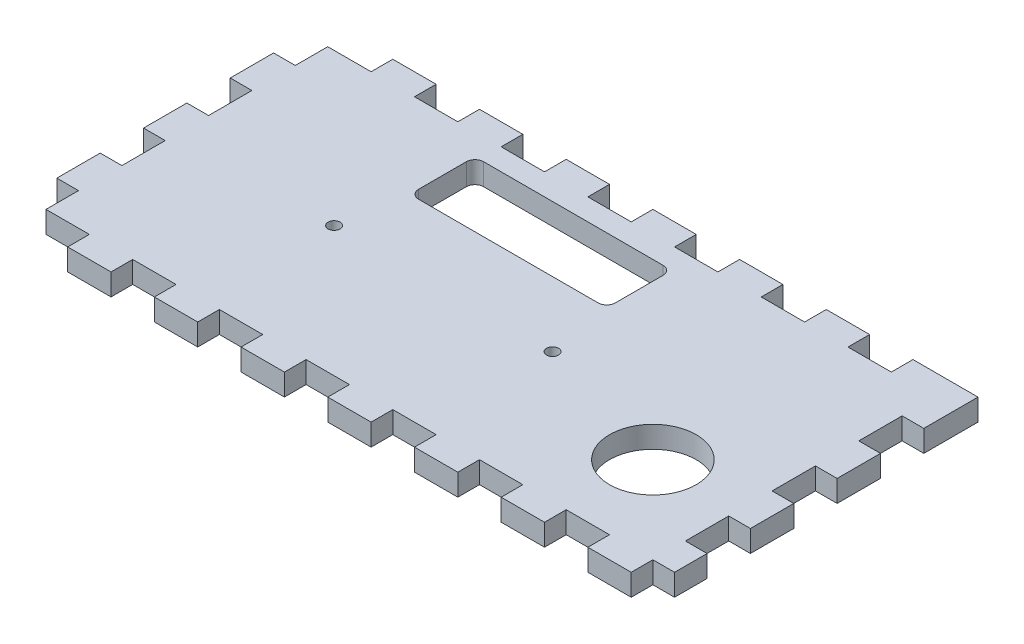
from build123d import *

# Parameters (mm, degrees)
SKETCH1_W           = 431.8
SKETCH1_H           = 95.25
BOSS_EXTRUDE1_DEPTH = 6.35
SKETCH2_W           = 12.7
SKETCH2_H           = 6.35
CUT_EXTRUDE1_DEPTH  = 7.35
LPATTERN1_COUNT     = 17
LPATTERN1_PITCH     = 25.4
SKETCH3_W           = 6.35
SKETCH3_H           = 6.35
CUT_EXTRUDE2_DEPTH  = 7.35
SKETCH5_W           = 6.35
SKETCH5_H           = 12.7
CUT_EXTRUDE4_DEPTH  = 7.35
LPATTERN2_COUNT     = 2
LPATTERN2_PITCH     = 25.4
LPATTERN2_COL_COUNT = 2
LPATTERN2_COL_PITCH = 25.4
SKETCH6_W           = 114.3
SKETCH6_H           = 46.0375
CUT_EXTRUDE5_DEPTH  = 7.35
SKETCH7_R           = 1.75
CUT_EXTRUDE6_DEPTH  = 7.35
SKETCH8_W           = 6.35
SKETCH8_H           = 9.525
SKETCH8_H_2         = 12.7
CUT_EXTRUDE7_DEPTH  = 7.35
LPATTERN3_COUNT     = 2
LPATTERN3_PITCH     = 425.45
SKETCH9_W           = 241.3
SKETCH9_H           = 95.25
CUT_EXTRUDE8_DEPTH  = 7.35
SKETCH11_W          = 6.35
SKETCH11_H          = 6.35
BOSS_EXTRUDE2_DEPTH = 6.35
SKETCH12_W          = 57.65
SKETCH12_H          = 19.05
CUT_EXTRUDE10_DEPTH = 7.35
FILLET1_R           = 2.54
SKETCH13_R          = 12.7
CUT_EXTRUDE11_DEPTH = 7.35


with BuildPart() as part:
    # Sketch1 → Boss-Extrude1 (new body)
    with BuildSketch(Plane(origin=(0, 0, 0), x_dir=(1, 0, 0), z_dir=(0, 1, 0))):
        with Locations((215.9, 47.625)):
            Rectangle(SKETCH1_W, SKETCH1_H)
    extrude(amount=BOSS_EXTRUDE1_DEPTH)

    # Sketch2 → Cut-Extrude1 (cut, through all)
    with BuildSketch(Plane(origin=(0, 6.35, 0), x_dir=(1, 0, 0), z_dir=(0, 1, 0))):
        with Locations((12.7, 92.075)):
            Rectangle(SKETCH2_W, SKETCH2_H)
        with Locations((12.7, 3.175)):
            Rectangle(SKETCH2_W, SKETCH2_H)
    cut_extrude1 = extrude(amount=-CUT_EXTRUDE1_DEPTH, mode=Mode.SUBTRACT)

    # LPattern1: Cut-Extrude1 ×17
    with Locations(*[(i * LPATTERN1_PITCH, 0, 0) for i in range(1, LPATTERN1_COUNT)]):
        add(cut_extrude1, mode=Mode.SUBTRACT)

    # Sketch3 → Cut-Extrude2 (cut, through all)
    with BuildSketch(Plane(origin=(0, 6.35, 0), x_dir=(1, 0, 0), z_dir=(0, 1, 0))):
        with Locations((3.175, 92.075)):
            Rectangle(SKETCH3_W, SKETCH3_H)
        with Locations((3.175, 3.175)):
            Rectangle(SKETCH3_W, SKETCH3_H)
        with Locations((428.625, 92.075)):
            Rectangle(SKETCH3_W, SKETCH3_H)
        with Locations((428.625, 3.175)):
            Rectangle(SKETCH3_W, SKETCH3_H)
    extrude(amount=-CUT_EXTRUDE2_DEPTH, mode=Mode.SUBTRACT)

    # Sketch5 → Cut-Extrude4 (cut, through all)
    with BuildSketch(Plane(origin=(0, 6.35, 0), x_dir=(1, 0, 0), z_dir=(0, 1, 0))):
        with Locations((187.325, 47.625)):
            Rectangle(SKETCH5_W, SKETCH5_H)
        with Locations((307.975, 47.625)):
            Rectangle(SKETCH5_W, SKETCH5_H)
    cut_extrude4 = extrude(amount=-CUT_EXTRUDE4_DEPTH, mode=Mode.SUBTRACT)

    # LPattern2: Cut-Extrude4 ×2
    with Locations(*[(0, 0, -i * LPATTERN2_PITCH) for i in range(1, LPATTERN2_COUNT)]):
        add(cut_extrude4, mode=Mode.SUBTRACT)

    # LPattern2 col: Cut-Extrude4 ×2
    with Locations(*[(0, 0, i * LPATTERN2_COL_PITCH) for i in range(1, LPATTERN2_COL_COUNT)]):
        add(cut_extrude4, mode=Mode.SUBTRACT)

    # Sketch6 → Cut-Extrude5 (cut, through all)
    with BuildSketch(Plane(origin=(0, 6.35, 0), x_dir=(1, 0, 0), z_dir=(0, 1, 0))):
        with Locations((247.65, 47.625)):
            Rectangle(SKETCH6_W, SKETCH6_H)
    extrude(amount=-CUT_EXTRUDE5_DEPTH, mode=Mode.SUBTRACT)

    # Sketch7 → Cut-Extrude6 (cut, through all)
    with BuildSketch(Plane(origin=(0, 6.35, 0), x_dir=(1, 0, 0), z_dir=(0, 1, 0))):
        with Locations((52.65, 44.45)):
            Circle(SKETCH7_R)
        with Locations((116.65, 44.45)):
            Circle(SKETCH7_R)
        with Locations((315.15, 44.45)):
            Circle(SKETCH7_R)
        with Locations((379.15, 44.45)):
            Circle(SKETCH7_R)
    extrude(amount=-CUT_EXTRUDE6_DEPTH, mode=Mode.SUBTRACT)

    # Sketch8 → Cut-Extrude7 (cut, through all)
    with BuildSketch(Plane(origin=(0, 6.35, 0), x_dir=(1, 0, 0), z_dir=(0, 1, 0))):
        with Locations((3.175, 84.1375)):
            Rectangle(SKETCH8_W, SKETCH8_H)
        with Locations((3.175, 11.1125)):
            Rectangle(SKETCH8_W, SKETCH8_H)
        with Locations((3.175, 34.925)):
            Rectangle(SKETCH8_W, SKETCH8_H_2)
        with Locations((3.175, 60.325)):
            Rectangle(SKETCH8_W, SKETCH8_H_2)
    cut_extrude7 = extrude(amount=-CUT_EXTRUDE7_DEPTH, mode=Mode.SUBTRACT)

    # LPattern3: Cut-Extrude7 ×2
    with Locations(*[(i * LPATTERN3_PITCH, 0, 0) for i in range(1, LPATTERN3_COUNT)]):
        add(cut_extrude7, mode=Mode.SUBTRACT)

    # Sketch9 → Cut-Extrude8 (cut, through all)
    with BuildSketch(Plane(origin=(0, 6.35, 0), x_dir=(1, 0, 0), z_dir=(0, 1, 0))):
        with Locations((311.15, 47.625)):
            Rectangle(SKETCH9_W, SKETCH9_H)
    extrude(amount=-CUT_EXTRUDE8_DEPTH, mode=Mode.SUBTRACT)

    # Sketch11 → Boss-Extrude2 (add, through all)
    with BuildSketch(Plane(origin=(0, 6.35, 0), x_dir=(1, 0, 0), z_dir=(0, 1, 0))):
        with Locations((187.325, 92.075)):
            Rectangle(SKETCH11_W, SKETCH11_H)
    extrude(amount=-BOSS_EXTRUDE2_DEPTH)

    # Sketch12 → Cut-Extrude10 (cut, through all)
    with BuildSketch(Plane(origin=(0, 6.35, 0), x_dir=(1, 0, 0), z_dir=(0, 1, 0))):
        with Locations((84.65, 73.025)):
            Rectangle(SKETCH12_W, SKETCH12_H)
    extrude(amount=-CUT_EXTRUDE10_DEPTH, mode=Mode.SUBTRACT)

    # Fillet1
    fillet1_edges = [part.edges().sort_by_distance(p)[0] for p in [
        (55.825, 3.175, -63.5),
        (55.825, 3.175, -82.55),
        (113.475, 3.175, -82.55),
        (113.475, 3.175, -63.5),
    ]]
    fillet(fillet1_edges, radius=FILLET1_R)

    # Sketch13 → Cut-Extrude11 (cut, through all)
    with BuildSketch(Plane(origin=(0, 6.35, 0), x_dir=(1, 0, 0), z_dir=(0, 1, 0))):
        with Locations((158.75, 31.75)):
            Circle(SKETCH13_R)
    extrude(amount=-CUT_EXTRUDE11_DEPTH, mode=Mode.SUBTRACT)


solid = part.part
